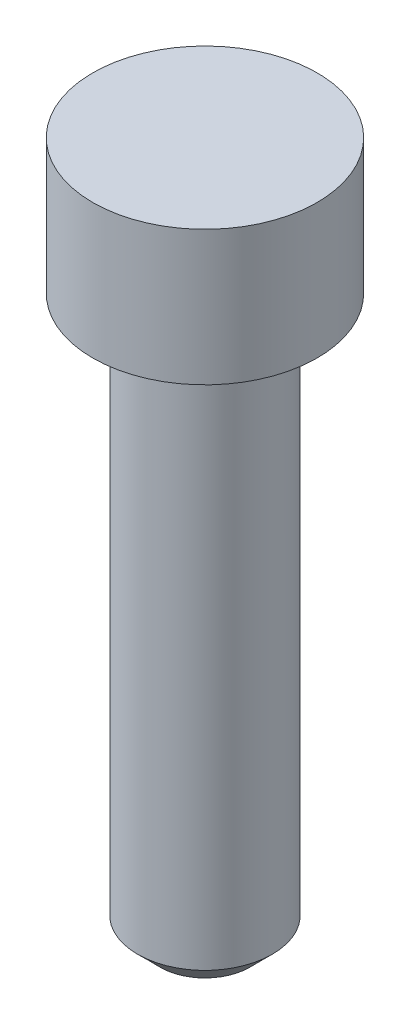
from build123d import *

# Parameters (mm, degrees)
SKETCH1_R           = 5
BOSS_EXTRUDE1_DEPTH = 6
SKETCH2_R           = 3
BOSS_EXTRUDE2_DEPTH = 25
CHAMFER1_SIZE       = 1


with BuildPart() as part:
    # Sketch1 → Boss-Extrude1 (new body)
    with BuildSketch(Plane(origin=(0, 0, 0), x_dir=(1, 0, 0), z_dir=(0, 1, 0))):
        Circle(SKETCH1_R)
    extrude(amount=BOSS_EXTRUDE1_DEPTH)

    # Sketch2 → Boss-Extrude2 (add)
    with BuildSketch(Plane.XZ):
        Circle(SKETCH2_R)
    extrude(amount=BOSS_EXTRUDE2_DEPTH)

    # Chamfer1
    chamfer1_edges = [part.edges().sort_by_distance(p)[0] for p in [
        (-3, -25, 0),
    ]]
    chamfer(chamfer1_edges, length=CHAMFER1_SIZE)


solid = part.part
